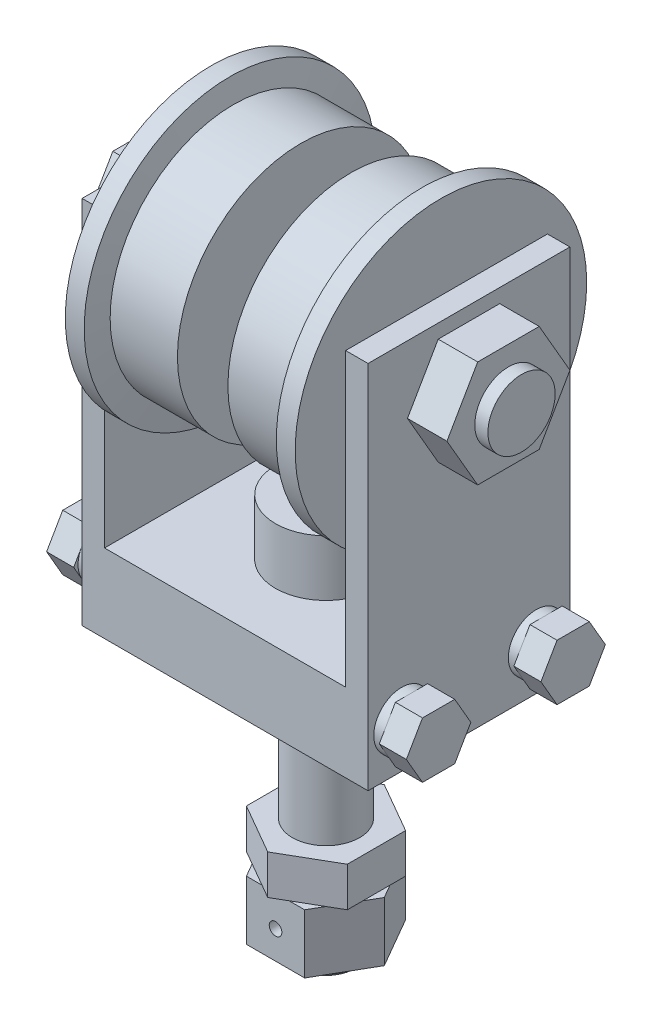
from build123d import *

# Parameters (mm, degrees)
YOKE_CROSS_SECTION_W           = 114.3
YOKE_CROSS_SECTION_H           = 44.45
YOKE_DEPTH                     = 68.2625
SIDEPLATE_PROFILE_W            = 114.3
SIDEPLATE_PROFILE_H            = 209.55
SIDEPLATE_DEPTH                = 12.7
WHEEL_PIN_NUT_DEPTH            = 22.352
WHEEL_PIN_PROJECTION_PROFILE_R = 19.05
WHEEL_PIN_PROJECTION_DEPTH     = 7.4168
LOCKNUTS_PROFILE_R             = 15.8115
LOCKNUTS_DEPTH                 = 5.5626
SCREWS_DEPTH                   = 15.3416
PROFILE_R                      = 28.575
KING_BOLT_HEAD_DEPTH           = 31.75
DIA_R                          = 19.05
KING_BOLT_DEPTH                = 82.55
KING_BOLT_JAM_NUT_DEPTH        = 22.352
KING_BOLT_NUT_DEPTH            = 33.4518
SKETCH5_R                      = 19.05
EXTENDED_KING_BOLT_DEPTH       = 9.525
CHAMFER1_SIZE                  = 2.38125
COTTER_PIN_HOLE_REACH          = 113.125
SKETCH7_R                      = 3.571875


with BuildPart() as part:
    # YOKE CROSS SECTION → YOKE (new body)
    with BuildSketch(Plane(origin=(0, 0, 0), x_dir=(0, 0, -1), z_dir=(1, 0, 0))):
        with Locations((0, 22.225)):
            Rectangle(YOKE_CROSS_SECTION_W, YOKE_CROSS_SECTION_H)
    extrude(amount=YOKE_DEPTH)

    # SIDEPLATE PROFILE → SIDEPLATE (add)
    with BuildSketch(Plane(origin=(68.2625, 0, 0), x_dir=(0, 0, -1), z_dir=(1, 0, 0))):
        with Locations((0, 104.775)):
            Rectangle(SIDEPLATE_PROFILE_W, SIDEPLATE_PROFILE_H)
    extrude(amount=SIDEPLATE_DEPTH)

    # WHEEL PIN NUT PROFILE → WHEEL PIN NUT (add)
    with BuildSketch(Plane(origin=(80.9625, 0, 0), x_dir=(0, 0, -1), z_dir=(1, 0, 0))):
        Polygon((34.828654989, 171.45), (17.414327494, 201.6125), (-17.414327494, 201.6125), (-34.828654989, 171.45), (-17.414327494, 141.2875), (17.414327494, 141.2875), align=None)
    extrude(amount=WHEEL_PIN_NUT_DEPTH)

    # WHEEL PIN PROJECTION PROFILE → WHEEL PIN PROJECTION (add)
    with BuildSketch(Plane(origin=(103.3145, 0, 0), x_dir=(0, 0, -1), z_dir=(1, 0, 0))):
        with Locations((0, 171.45)):
            Circle(WHEEL_PIN_PROJECTION_PROFILE_R)
    extrude(amount=WHEEL_PIN_PROJECTION_DEPTH)

    # LOCKNUTS PROFILE → LOCKNUTS (add)
    with BuildSketch(Plane(origin=(80.9625, 0, 0), x_dir=(0, 0, -1), z_dir=(1, 0, 0))):
        with Locations((-38.1, 25.4)):
            Circle(LOCKNUTS_PROFILE_R)
    locknuts = extrude(amount=LOCKNUTS_DEPTH)

    # SCREWS PROFILE → SCREWS (add)
    with BuildSketch(Plane(origin=(86.5251, 0, 0), x_dir=(0, 0, -1), z_dir=(1, 0, 0))):
        Polygon((-19.842452437, 25.4), (-28.971226219, 41.2115), (-47.228773781, 41.2115), (-56.357547563, 25.4), (-47.228773781, 9.5885), (-28.971226219, 9.5885), align=None)
    screws = extrude(amount=SCREWS_DEPTH)

    # PROFILE → KING BOLT HEAD (add)
    with BuildSketch(Plane(origin=(0, 44.45, 0), x_dir=(-1, 0, 0), z_dir=(0, 1, 0))):
        with Locations(Location((0, 0, 0), (0, 0, 90))):  # turned: the seam where the file's is
            Circle(PROFILE_R)
    extrude(amount=KING_BOLT_HEAD_DEPTH)

    # Mirror1: LOCKNUTS, SCREWS across plane
    add(locknuts.mirror(Plane.XY))
    add(screws.mirror(Plane.XY))

    # Mirror5: part across plane


with BuildPart() as part_1:
    add(part.part)
    add(part.part.mirror(Plane(origin=(0, 0, 0), x_dir=(0, 0, 1), z_dir=(1, 0, 0))))

    # DIA. → KING BOLT (add)
    with BuildSketch(Plane.XZ):
        with Locations(Location((0, 0, 0), (0, 0, 90))):  # turned: the seam where the file's is
            Circle(DIA_R)
    extrude(amount=KING_BOLT_DEPTH)

    # KING BOLT JAN NUT PROFILE → KING BOLT JAM NUT (add)
    with BuildSketch(Plane.XZ.offset(82.55)):
        Polygon((0, -32.995567884), (28.575, -16.497783942), (28.575, 16.497783942), (0, 32.995567884), (-28.575, 16.497783942), (-28.575, -16.497783942), align=None)
    extrude(amount=KING_BOLT_JAM_NUT_DEPTH)

    # KING BOLT NUT PROFILE → KING BOLT NUT (add)
    with BuildSketch(Plane.XZ.offset(104.902)):
        Polygon((32.995567884, 0), (16.497783942, 28.575), (-16.497783942, 28.575), (-32.995567884, 0), (-16.497783942, -28.575), (16.497783942, -28.575), align=None)
    extrude(amount=KING_BOLT_NUT_DEPTH)

    # Sketch5 → EXTENDED KING BOLT (add)
    with BuildSketch(Plane.XZ.offset(138.3538)):
        with Locations(Location((0, 0, 0), (0, 0, 90))):  # turned: the seam where the file's is
            Circle(SKETCH5_R)
    extrude(amount=EXTENDED_KING_BOLT_DEPTH)

    # Chamfer1
    chamfer1_edges = [part_1.edges().sort_by_distance(p)[0] for p in [
        (0, -147.8788, -19.05),
    ]]
    chamfer(chamfer1_edges, length=CHAMFER1_SIZE)

    # Sketch6 → WHEEL (revolve)
    with BuildSketch(Plane.XY, mode=Mode.PRIVATE) as wheel_sk:
        Polygon((68.2625, 198.4375), (65.0875, 198.4375), (65.0875, 254), (54.398982392, 254), (52.3875, 241.3), (14.2875, 241.3), (14.2875, 171.45), (68.2625, 171.45), align=None)
    wheel = revolve(wheel_sk.sketch.rotate(Axis((68.2625, 171.45, 0), (-1, 0, 0)), 90), axis=Axis((68.2625, 171.45, 0), (-1, 0, 0)))  # turned: the seam where the file's is

    # Mirror6: WHEEL across plane
    add(wheel.mirror(Plane(origin=(0, 0, 0), x_dir=(0, 0, 1), z_dir=(1, 0, 0))))

    # Sketch7 → COTTER PIN HOLE (cut, up to next)
    with BuildSketch(Plane.XY.offset(28.575), mode=Mode.PRIVATE) as cotter_pin_hole_sk1:
        with Locations((0, -122.4788)):
            Circle(SKETCH7_R)
    cotter_pin_hole_tool1 = extrude(cotter_pin_hole_sk1.sketch, amount=-COTTER_PIN_HOLE_REACH, mode=Mode.PRIVATE) & part_1.part
    add(cotter_pin_hole_tool1.solids().sort_by_distance((0, -122.4788, 28.575))[0], mode=Mode.SUBTRACT)


solid = part_1.part
